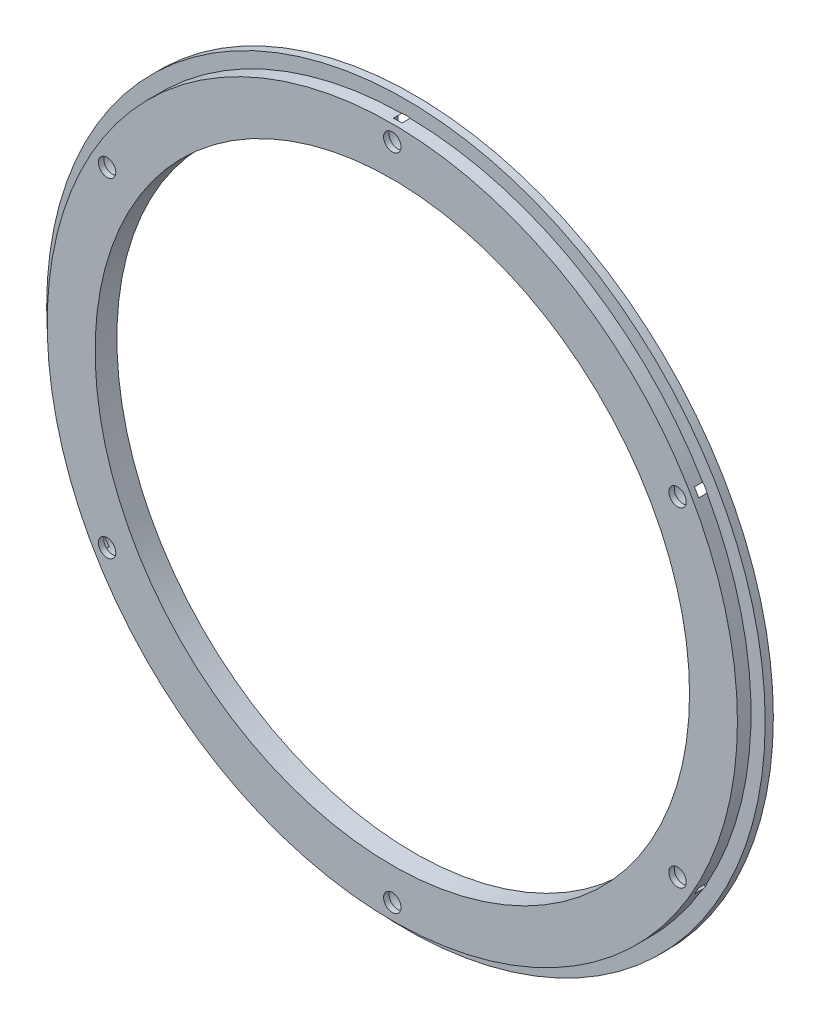
from build123d import *

# Parameters (mm, degrees)
SKETCH1_R           = 66
BOSS_EXTRUDE1_DEPTH = 1.5
SKETCH2_R           = 63.4
BOSS_EXTRUDE2_DEPTH = 2.5
SKETCH3_R           = 54.6
CUT_EXTRUDE1_DEPTH  = 10
SKETCH4_R           = 1.6
CUT_EXTRUDE2_DEPTH  = 10
SKETCH5_R           = 3
CUT_EXTRUDE3_DEPTH  = 3


with BuildPart() as part:
    # Sketch1 → Boss-Extrude1 (new body)
    with BuildSketch(Plane.XY):
        Circle(SKETCH1_R)
    extrude(amount=BOSS_EXTRUDE1_DEPTH)

    # Sketch2 → Boss-Extrude2 (add)
    with BuildSketch(Plane.XY.offset(1.5)):
        Circle(SKETCH2_R)
    extrude(amount=BOSS_EXTRUDE2_DEPTH)

    # Sketch3 → Cut-Extrude1 (cut)
    with BuildSketch(Plane.XY.offset(4)):
        Circle(SKETCH3_R)
    extrude(amount=-CUT_EXTRUDE1_DEPTH, mode=Mode.SUBTRACT)

    # Sketch4 → Cut-Extrude2 (cut)
    with BuildSketch(Plane.XY.offset(4)):
        with Locations((0, 60.5)):
            Circle(SKETCH4_R)
        with Locations((52.394536929, 30.25)):
            Circle(SKETCH4_R)
        with Locations((52.394536929, -30.25)):
            Circle(SKETCH4_R)
        with Locations((0, -60.5)):
            Circle(SKETCH4_R)
        with Locations((-52.394536929, -30.25)):
            Circle(SKETCH4_R)
        with Locations((-52.394536929, 30.25)):
            Circle(SKETCH4_R)
    extrude(amount=-CUT_EXTRUDE2_DEPTH, mode=Mode.SUBTRACT)

    # Sketch5 → Cut-Extrude3 (cut)
    with BuildSketch(Plane(origin=(0, 0, 0), x_dir=(-1, 0, 0), z_dir=(0, 0, -1))):
        with Locations((-52.394536929, 30.25)):
            Circle(SKETCH5_R)
        with Locations((0, 60.5)):
            Circle(SKETCH5_R)
        with Locations((-52.394536929, -30.25)):
            Circle(SKETCH5_R)
        with Locations((0, -60.5)):
            Circle(SKETCH5_R)
        with Locations((52.394536929, -30.25)):
            Circle(SKETCH5_R)
        with Locations((52.394536929, 30.25)):
            Circle(SKETCH5_R)
    extrude(amount=-CUT_EXTRUDE3_DEPTH, mode=Mode.SUBTRACT)


solid = part.part
